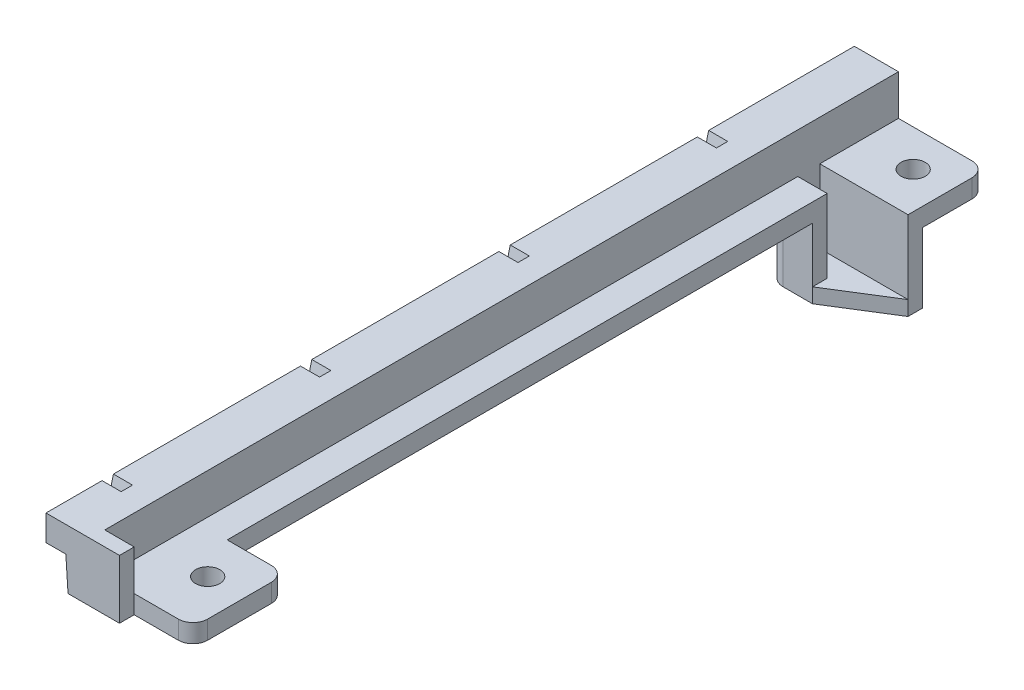
from build123d import *

# Parameters (mm, degrees)
SIDE_LIP_MAIN_SECTION_W          = 6
SIDE_LIP_MAIN_SECTION_H          = 108
SIDE_LIP_DEPTH                   = 5
VERTICAL_FIN_CUTS_DEPTH          = 2.6
SKETCH4_W                        = 3.5
SKETCH4_H                        = 108
DESCENDER_DEPTH                  = 4.5
SKETCH5_W                        = 108
SKETCH5_H                        = 2.5
PCB_BASE_DEPTH                   = 4
LOWER_CAP_DEPTH                  = 2
SKETCH9_W                        = 3
SKETCH9_H                        = 2.5
AL_BAR_CUT_DEPTH                 = 4
SKETCH10_W                       = 12.653731328
SKETCH10_H                       = 2.5
SKETCH10_W_2                     = 10.7
SUPPORT_TABS_DEPTH               = 8
BOLT_HOLES_REACH                 = 4.5
SKETCH11_R                       = 1.65
AL_BAR_ENCLOSURE_DEPTH           = 7.5
AL_BAR_BASE_DEPTH                = 2
FILLET1_R                        = 2
SKETCH16_W                       = 10
SKETCH16_H                       = 0.5
REDUCE_SIDE_SUPPORT_HEIGHT_DEPTH = 111
SIT_FLAT_DEPTH                   = 111
SKETCH19_W                       = 110
SKETCH19_H                       = 1
LOWER_TOP_DEPTH                  = 19


with BuildPart() as part:
    # Side lip main section → Side lip (new body)
    with BuildSketch(Plane(origin=(0, 0, 0), x_dir=(1, 0, 0), z_dir=(0, 1, 0))):
        with Locations((3, -54)):
            Rectangle(SIDE_LIP_MAIN_SECTION_W, SIDE_LIP_MAIN_SECTION_H)
    extrude(amount=-SIDE_LIP_DEPTH)

    # Sketch2 → Vertical fin cuts (cut)
    with BuildSketch(Plane.ZY):
        Polygon((102, 0), (103.246640014, -5), (101.70071957, -5), (100.454079556, 0), align=None)
        Polygon((75, 0), (76.246640014, -5), (74.70071957, -5), (73.454079556, 0), align=None)
        Polygon((48, 0), (49.246640014, -5), (47.70071957, -5), (46.454079556, 0), align=None)
        Polygon((21, 0), (22.246640014, -5), (20.70071957, -5), (19.454079556, 0), align=None)
    extrude(amount=-VERTICAL_FIN_CUTS_DEPTH, mode=Mode.SUBTRACT)

    # Sketch4 → Descender (add)
    with BuildSketch(Plane.XZ.offset(5)):
        with Locations((4.25, 54)):
            Rectangle(SKETCH4_W, SKETCH4_H)
    extrude(amount=DESCENDER_DEPTH)

    # Sketch5 → PCB base (add)
    with BuildSketch(Plane(origin=(6, 0, 0), x_dir=(0, 0, -1), z_dir=(1, 0, 0))):
        with Locations((-54, -8.25)):
            Rectangle(SKETCH5_W, SKETCH5_H)
    extrude(amount=PCB_BASE_DEPTH)

    # Sketch8 → Lower cap (add)
    with BuildSketch(Plane.XY.offset(108)):
        Polygon((6, 0), (10, 0), (10, -7), (10, -9.5), (2.5, -9.5), (2.5, -5), (0, -5), (0, 0), align=None)
    extrude(amount=LOWER_CAP_DEPTH)

    # Sketch9 → Al bar cut (cut)
    with BuildSketch(Plane(origin=(10, 0, 0), x_dir=(0, 0, -1), z_dir=(1, 0, 0))):
        with Locations((-12.2, -8.25)):
            Rectangle(SKETCH9_W, SKETCH9_H)
    extrude(amount=-AL_BAR_CUT_DEPTH, mode=Mode.SUBTRACT)

    # Sketch10 → Support tabs (add)
    with BuildSketch(Plane(origin=(10, 0, 0), x_dir=(0, 0, -1), z_dir=(1, 0, 0))):
        with Locations((-101.673134336, -8.25)):
            Rectangle(SKETCH10_W, SKETCH10_H)
        with Locations((-5.35, -8.25)):
            Rectangle(SKETCH10_W_2, SKETCH10_H)
    extrude(amount=SUPPORT_TABS_DEPTH)

    # Sketch11 → Bolt holes (cut, up to next)
    with BuildSketch(Plane(origin=(0, -7, 0), x_dir=(1, 0, 0), z_dir=(0, 1, 0)), mode=Mode.PRIVATE) as bolt_holes_sk1:
        with Locations((13, -5)):
            Circle(SKETCH11_R)
    bolt_holes_tool1 = extrude(bolt_holes_sk1.sketch, amount=-BOLT_HOLES_REACH, mode=Mode.PRIVATE) & part.part
    add(bolt_holes_tool1.solids().sort_by_distance((13, -7, 5))[0], mode=Mode.SUBTRACT)
    # Sketch11 → Bolt holes (cut, up to next)
    with BuildSketch(Plane(origin=(0, -7, 0), x_dir=(1, 0, 0), z_dir=(0, 1, 0)), mode=Mode.PRIVATE) as bolt_holes_sk2:
        with Locations((13, -101)):
            Circle(SKETCH11_R)
    bolt_holes_tool2 = extrude(bolt_holes_sk2.sketch, amount=-BOLT_HOLES_REACH, mode=Mode.PRIVATE) & part.part
    add(bolt_holes_tool2.solids().sort_by_distance((13, -7, 101))[0], mode=Mode.SUBTRACT)

    # Sketch12 → Al bar enclosure (add)
    with BuildSketch(Plane.XZ.offset(9.5)):
        Polygon((6, 10.7), (18, 10.7), (18, 8.7), (4, 8.7), (4, 15.7), (10, 15.7), (10, 13.7), (6, 13.7), align=None)
    extrude(amount=AL_BAR_ENCLOSURE_DEPTH)

    # Sketch13 → Al bar base (add)
    with BuildSketch(Plane.XZ.offset(17)):
        Polygon((10, 15.7), (4, 15.7), (4, 8.7), (18, 8.7), (18, 10.7), align=None)
    extrude(amount=AL_BAR_BASE_DEPTH)

    # Fillet1
    fillet1_edges = [part.edges().sort_by_distance(p)[0] for p in [
        (18, -8.25, 108),
        (18, -8.25, 95.346268672),
        (18, -8.25, 0),
        (4, -14.25, 15.7),
        (4, -14.25, 8.7),
    ]]
    fillet(fillet1_edges, radius=FILLET1_R)

    # Sketch16 → Reduce side support height (cut, through all)
    with BuildSketch(Plane.XY.offset(110)):
        with Locations((5, -0.25)):
            Rectangle(SKETCH16_W, SKETCH16_H)
    extrude(amount=-REDUCE_SIDE_SUPPORT_HEIGHT_DEPTH, mode=Mode.SUBTRACT)

    # Sketch17 → Sit flat! (cut, through all)
    with BuildSketch(Plane.XY.offset(110)):
        Polygon((2.5, -5), (2.7, -5), (3, -9.5), (2.5, -9.5), align=None)
    extrude(amount=-SIT_FLAT_DEPTH, mode=Mode.SUBTRACT)

    # Sketch19 → Lower top (cut, through all)
    with BuildSketch(Plane.ZY):
        with Locations((55, -1)):
            Rectangle(SKETCH19_W, SKETCH19_H)
    extrude(amount=-LOWER_TOP_DEPTH, mode=Mode.SUBTRACT)


solid = part.part
